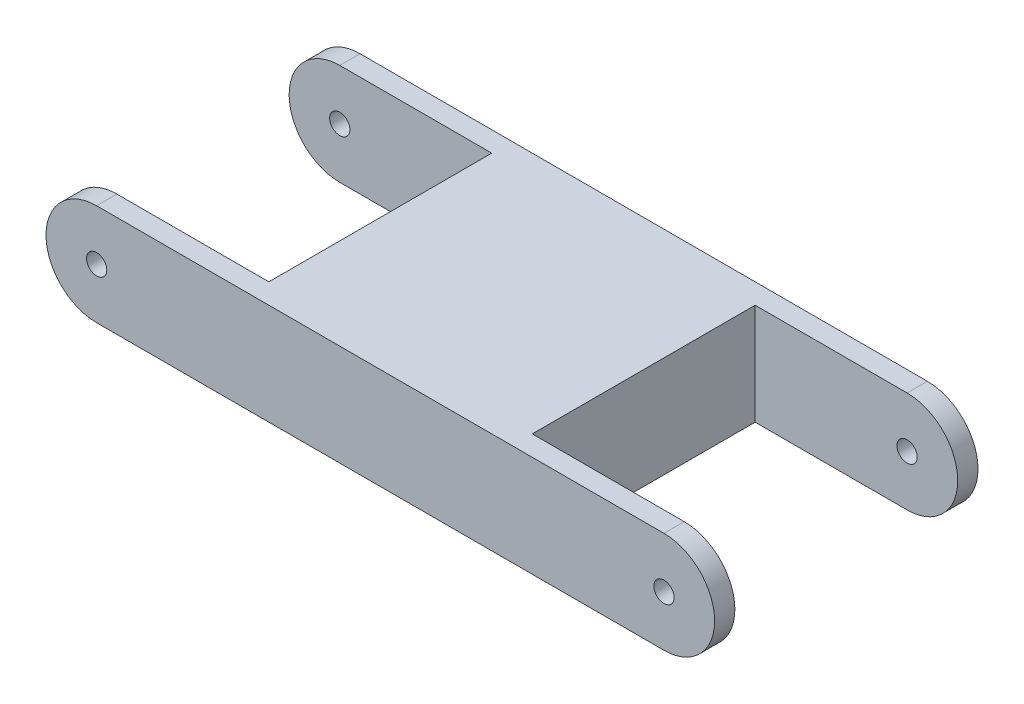
from build123d import *

# Parameters (mm, degrees)
EXTRUDE_1_DEPTH          = 26
SKETCH_2_R               = 1
CUT_EXTRUDE_4_DEPTH      = 27
CUT_EXTRUDE_4_DEPTH_BACK = 30
SKETCH_3_W               = 20
SKETCH_3_H               = 22
CUT_EXTRUDE_5_DEPTH      = 30
CUT_EXTRUDE_5_DEPTH_BACK = 30


with BuildPart() as part:
    # 草圖1 → 填料-伸長1 (new body)
    with BuildSketch(Plane.XY):
        with BuildLine():
            Line((-28, 5), (28, 5))
            ThreePointArc((28, 5), (33, 0), (28, -5))
            Line((28, -5), (-28, -5))
            ThreePointArc((-28, -5), (-33, 0), (-28, 5))
        make_face()
    extrude(amount=EXTRUDE_1_DEPTH)

    # 草圖2 → 除料-伸長4 (cut, two sides)
    with BuildSketch(Plane.XY) as cut_extrude_4_sk:
        with Locations((-28, 0)):
            Circle(SKETCH_2_R)
        with Locations((28, 0)):
            Circle(SKETCH_2_R)
    extrude(amount=CUT_EXTRUDE_4_DEPTH, mode=Mode.SUBTRACT)
    extrude(cut_extrude_4_sk.sketch, amount=-CUT_EXTRUDE_4_DEPTH_BACK, mode=Mode.SUBTRACT)

    # 草圖3 → 除料-伸長5 (cut, two sides)
    with BuildSketch(Plane(origin=(0, 0, 0), x_dir=(1, 0, 0), z_dir=(0, 1, 0))) as cut_extrude_5_sk:
        with Locations((-23, -13)):
            Rectangle(SKETCH_3_W, SKETCH_3_H)
        with Locations((23, -13)):
            Rectangle(SKETCH_3_W, SKETCH_3_H)
    extrude(amount=CUT_EXTRUDE_5_DEPTH, mode=Mode.SUBTRACT)
    extrude(cut_extrude_5_sk.sketch, amount=-CUT_EXTRUDE_5_DEPTH_BACK, mode=Mode.SUBTRACT)


solid = part.part
